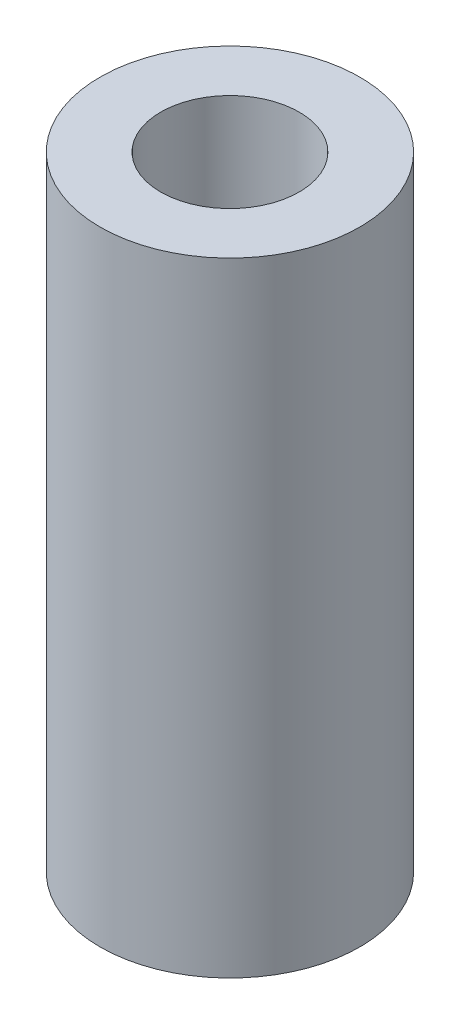
from build123d import *

# Parameters (mm, degrees)
ESQUISSE1_R      = 7.5
ESQUISSE1_R_2    = 4
EXTRUSION1_DEPTH = 36


with BuildPart() as part:
    # Esquisse1 → Extrusion1 (new body)
    with BuildSketch(Plane(origin=(0, 0, 0), x_dir=(1, 0, 0), z_dir=(0, 1, 0))):
        Circle(ESQUISSE1_R)
        Circle(ESQUISSE1_R_2, mode=Mode.SUBTRACT)
    extrude(amount=EXTRUSION1_DEPTH)


solid = part.part
